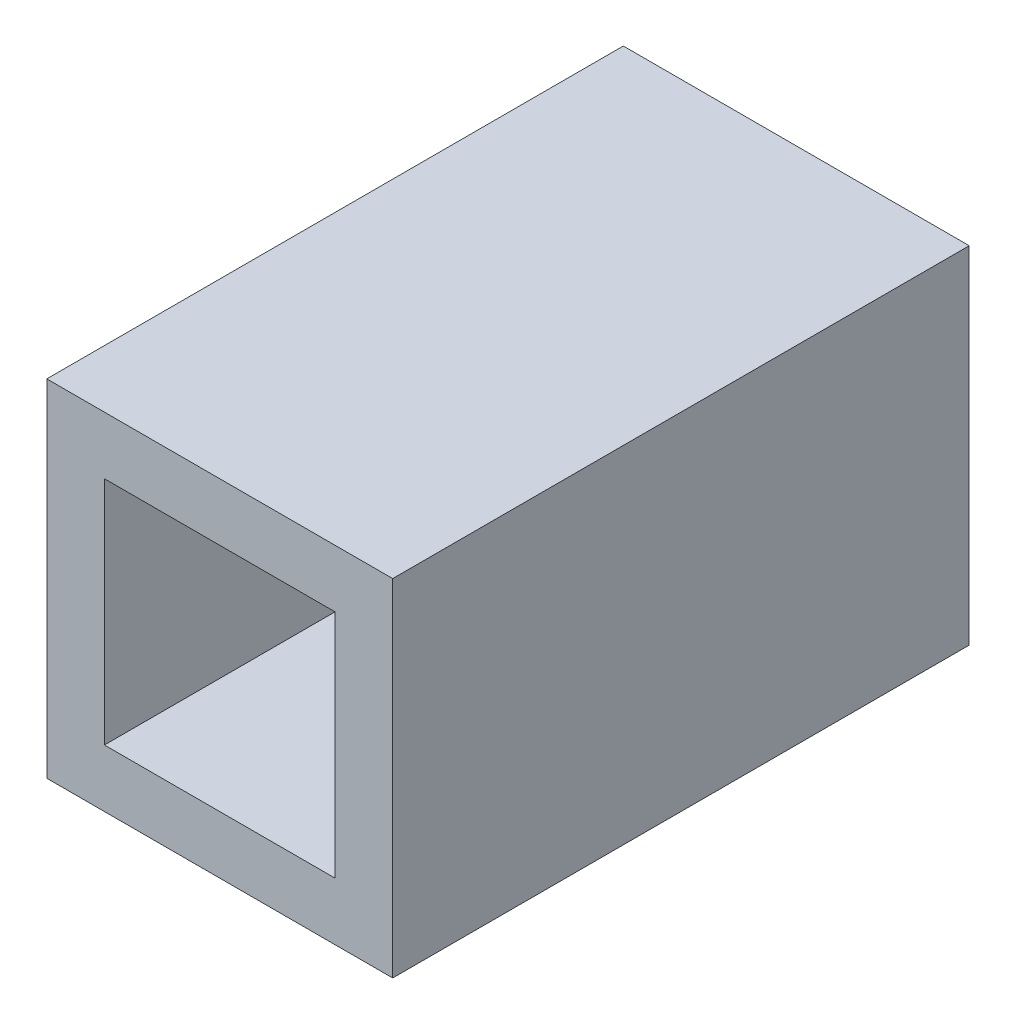
from build123d import *

# Parameters (mm, degrees)
SKETCH1_W           = 6
SKETCH1_H           = 6
SKETCH1_W_2         = 4
SKETCH1_H_2         = 4
BOSS_EXTRUDE1_DEPTH = 10


with BuildPart() as part:
    # Sketch1 → Boss-Extrude1 (new body)
    with BuildSketch(Plane.XY):
        with Locations((2, 2)):
            Rectangle(SKETCH1_W, SKETCH1_H)
        with Locations((2, 2)):
            Rectangle(SKETCH1_W_2, SKETCH1_H_2, mode=Mode.SUBTRACT)
    extrude(amount=BOSS_EXTRUDE1_DEPTH)


solid = part.part
